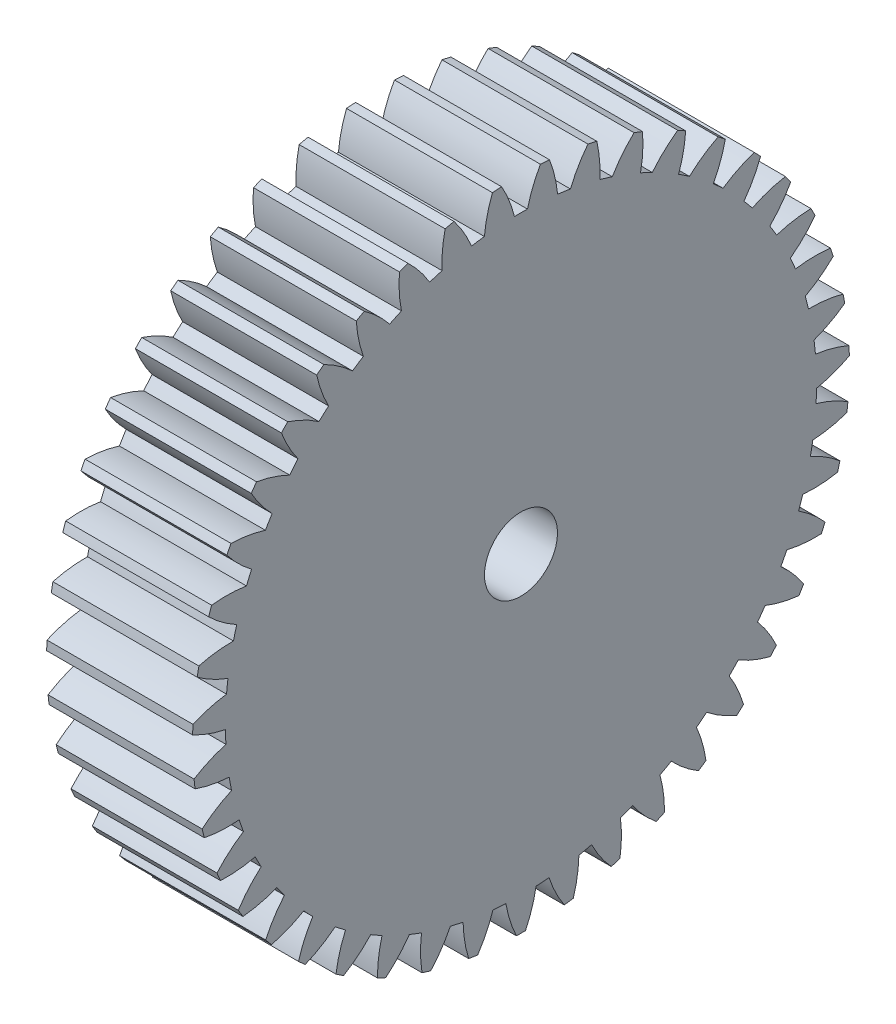
from build123d import *

# Parameters (mm, degrees)
BASPROSKE_W     = 10
BASPROSKE_H     = 22.5
TOOTHCUT_DEPTH  = 34.35416016
TEETHCUTS_COUNT = 43
TEETHCUTS_ANGLE = 351.627906977
BORSKE_R        = 2.5
BORE_DEPTH      = 50.0000508


with BuildPart() as part:
    # BasProSke → Base-Revolve (revolve)
    with BuildSketch(Plane(origin=(0, 0, 0), x_dir=(1, 0, 0), z_dir=(0, 1, 0)), mode=Mode.PRIVATE) as base_revolve_sk:
        with Locations((5, 11.25)):
            Rectangle(BASPROSKE_W, BASPROSKE_H)
    revolve(base_revolve_sk.sketch.rotate(Axis((-10, 0, 0), (1, 0, 0)), 180), axis=Axis((-10, 0, 0), (1, 0, 0)))

    # TooCutSke → ToothCut (cut, through all)
    with BuildSketch(Plane(origin=(0, 0, 0), x_dir=(0, 0, -1), z_dir=(1, 0, 0))):
        with BuildLine():
            ThreePointArc((0.444866364, 20.244112599), (0, 20.249), (-0.444866364, 20.244112599))
            ThreePointArc((-0.444866364, 20.244112599), (-0.81630868, 21.396424265), (-1.345889069, 22.48515572))
            ThreePointArc((-1.345889069, 22.48515572), (0, 22.5254), (1.345889069, 22.48515572))
            ThreePointArc((1.345889069, 22.48515572), (0.81630868, 21.396424265), (0.444866364, 20.244112599))
        make_face()
    toothcut = extrude(amount=TOOTHCUT_DEPTH, mode=Mode.SUBTRACT)

    # TeethCuts: ToothCut ×43 about axis
    teethcuts_axis = Axis((-10, 0, 0), (1, 0, 0))
    for i in range(1, TEETHCUTS_COUNT):
        add(toothcut.rotate(teethcuts_axis, i * TEETHCUTS_ANGLE / (TEETHCUTS_COUNT - 1)), mode=Mode.SUBTRACT)

    # BorSke → Bore (cut, symmetric)
    with BuildSketch(Plane(origin=(0, 0, 0), x_dir=(0, 0, -1), z_dir=(1, 0, 0))):
        with Locations(Location((0, 0, 0), (0, 0, 180))):
            Circle(BORSKE_R)
    extrude(amount=BORE_DEPTH, both=True, mode=Mode.SUBTRACT)


solid = part.part
